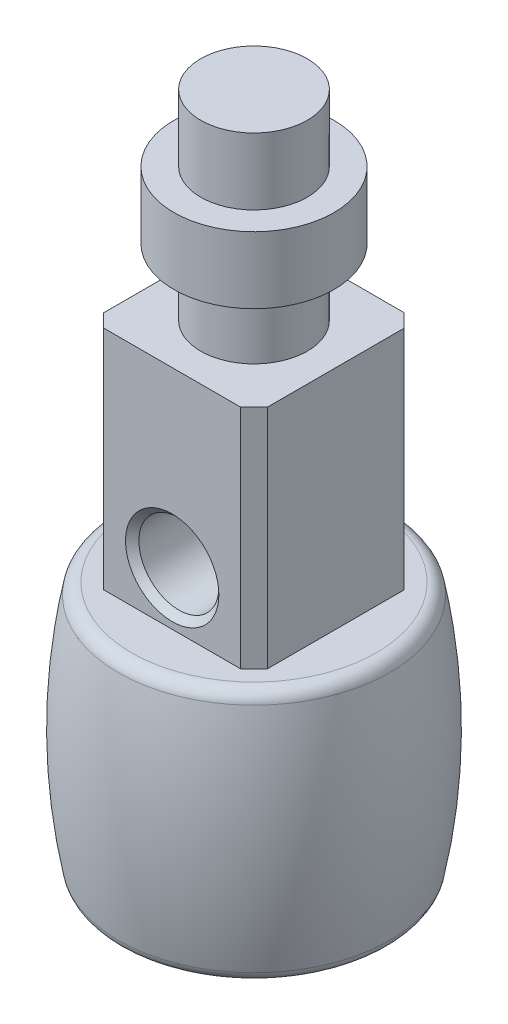
from build123d import *

# Parameters (mm, degrees)
SKETCH2_OUTSIDE_W   = 35.948
SKETCH2_OUTSIDE_H   = 35.948
CUT_EXTRUDE1_DEPTH  = 17
SKETCH3_R           = 3
CUT_EXTRUDE2_DEPTH  = 8.269428
CHAMFER1_SIZE       = 0.5
SKETCH4_R           = 5
BOSS_EXTRUDE1_DEPTH = 1
FILLET1_R           = 1


with BuildPart() as part:
    # Sketch1 → Revolve1 (revolve)
    with BuildSketch(Plane.XY):
        with BuildLine():
            Line((0, 0), (0, 51))
            Line((0, 51), (4, 51))
            Line((4, 51), (4, 46.000706479))
            Line((4, 46.000706479), (6, 46.000706479))
            Line((6, 46.000706479), (6, 40.999293521))
            Line((6, 40.999293521), (4, 40.999293521))
            Line((4, 40.999293521), (4, 36))
            Line((4, 36), (8, 36))
            Line((8, 36), (8, 19))
            Line((8, 19), (10, 19))
            ThreePointArc((10, 19), (11, 9.5), (10, 0))
            Line((10, 0), (0, 0))
        make_face()
    revolve(axis=Axis((0, 0, 0), (0, 1, 0)))

    # Sketch2 outside → Cut-Extrude1 (cut)
    with BuildSketch(Plane(origin=(0, 36, 0), x_dir=(1, 0, 0), z_dir=(0, 1, 0))):
        Rectangle(SKETCH2_OUTSIDE_W, SKETCH2_OUTSIDE_H)
        Polygon((-6.134713835, 5.134713835), (-5.134713835, 6.134713835), (5.134713835, 6.134713835), (6.134713835, 5.134713835), (6.134713835, -5.134713835), (5.134713835, -6.134713835), (-5.134713835, -6.134713835), (-6.134713835, -5.134713835), align=None, mode=Mode.SUBTRACT)
    extrude(amount=-CUT_EXTRUDE1_DEPTH, mode=Mode.SUBTRACT)

    # Sketch3 → Cut-Extrude2 (cut)
    with BuildSketch(Plane.XY.offset(6.134713835)):
        with Locations((0.000286165, 23)):
            Circle(SKETCH3_R)
    extrude(amount=-CUT_EXTRUDE2_DEPTH, mode=Mode.SUBTRACT)

    # Chamfer1
    chamfer1_edges = [part.edges().sort_by_distance(p)[0] for p in [
        (-2.999713835, 23, 6.134713835),
    ]]
    chamfer(chamfer1_edges, length=CHAMFER1_SIZE)

    # Sketch4 → Boss-Extrude1 (add)
    with BuildSketch(Plane.XZ):
        Circle(SKETCH4_R)
    extrude(amount=BOSS_EXTRUDE1_DEPTH)

    # Fillet1
    fillet1_edges = [part.edges().sort_by_distance(p)[0] for p in [
        (-10, 0, 0),
        (-10, 19, 0),
    ]]
    fillet(fillet1_edges, radius=FILLET1_R)


solid = part.part
